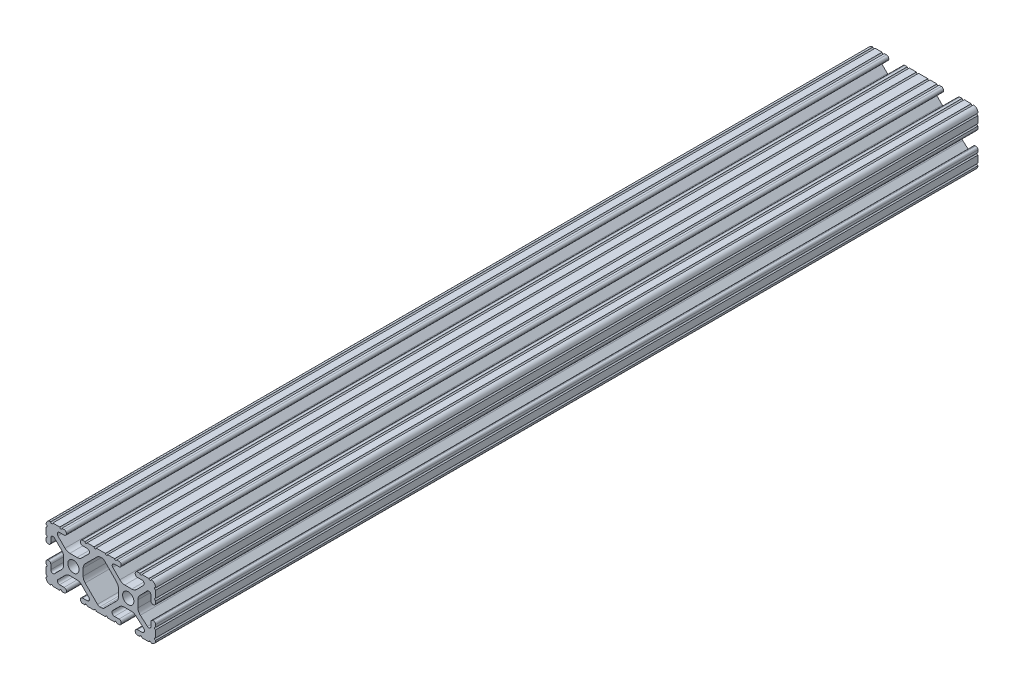
from build123d import *

# Parameters (mm, degrees)
SKETCH1_R           = 2.6035
BOSS_EXTRUDE1_DEPTH = 190.5


with BuildPart() as part:
    # Sketch1 → Boss-Extrude1 (new body, symmetric)
    with BuildSketch(Plane.XY):
        with BuildLine():
            Line((18.01710265, 12.7), (16.98745015, 12.7))
            ThreePointArc((16.98745015, 12.7), (16.245730386, 12.392769614), (15.9385, 11.65104985))
            Line((15.9385, 11.65104985), (15.9385, 11.53922))
            ThreePointArc((15.9385, 11.53922), (16.245750844, 10.797450844), (16.98752, 10.4902))
            Line((16.98752, 10.4902), (19.116384363, 10.4902))
            ThreePointArc((19.116384363, 10.4902), (20.052502933, 9.869096983), (19.844087081, 8.765172272))
            Line((19.844087081, 8.765172272), (16.618993479, 5.455112286))
            ThreePointArc((16.618993479, 5.455112286), (15.578994274, 4.745442459), (14.344932584, 4.4958))
            Line((14.344932584, 4.4958), (11.083317835, 4.4958))
            ThreePointArc((11.083317835, 4.4958), (9.854330953, 4.743306833), (8.816955189, 5.447238587))
            Line((8.816955189, 5.447238587), (5.564154119, 8.762652677))
            ThreePointArc((5.564154119, 8.762652677), (5.352591412, 9.867473037), (6.289393385, 10.4902))
            Line((6.289393385, 10.4902), (8.41248, 10.4902))
            ThreePointArc((8.41248, 10.4902), (9.154249156, 10.797450844), (9.4615, 11.53922))
            Line((9.4615, 11.53922), (9.4615, 11.65104985))
            ThreePointArc((9.4615, 11.65104985), (9.154269614, 12.392769614), (8.41254985, 12.7))
            Line((8.41254985, 12.7), (7.38288465, 12.7))
            ThreePointArc((7.38288465, 12.7), (6.87488465, 12.192), (6.36688465, 12.7))
            Line((6.36688465, 12.7), (3.14958095, 12.7))
            ThreePointArc((3.14958095, 12.7), (2.64158095, 12.192), (2.13358095, 12.7))
            Line((2.13358095, 12.7), (-2.13358095, 12.7))
            ThreePointArc((-2.13358095, 12.7), (-2.64158095, 12.192), (-3.14958095, 12.7))
            Line((-3.14958095, 12.7), (-6.36689735, 12.7))
            ThreePointArc((-6.36689735, 12.7), (-6.87489735, 12.192), (-7.38289735, 12.7))
            Line((-7.38289735, 12.7), (-8.41254985, 12.7))
            ThreePointArc((-8.41254985, 12.7), (-9.154269614, 12.392769614), (-9.4615, 11.65104985))
            Line((-9.4615, 11.65104985), (-9.4615, 11.53922))
            ThreePointArc((-9.4615, 11.53922), (-9.154249156, 10.797450844), (-8.41248, 10.4902))
            Line((-8.41248, 10.4902), (-6.283641037, 10.4902))
            ThreePointArc((-6.283641037, 10.4902), (-5.297291557, 9.829633109), (-5.532576693, 8.666071843))
            Line((-5.532576693, 8.666071843), (-8.809985098, 5.416263103))
            ThreePointArc((-8.809985098, 5.416263103), (-9.836720513, 4.734920264), (-11.045536121, 4.4958))
            Line((-11.045536121, 4.4958), (-14.354463879, 4.4958))
            ThreePointArc((-14.354463879, 4.4958), (-15.563279487, 4.734920264), (-16.590014902, 5.416263103))
            Line((-16.590014902, 5.416263103), (-19.867423307, 8.666071843))
            ThreePointArc((-19.867423307, 8.666071843), (-20.102708443, 9.829633109), (-19.116358963, 10.4902))
            Line((-19.116358963, 10.4902), (-16.98752, 10.4902))
            ThreePointArc((-16.98752, 10.4902), (-16.245750844, 10.797450844), (-15.9385, 11.53922))
            Line((-15.9385, 11.53922), (-15.9385, 11.65104985))
            ThreePointArc((-15.9385, 11.65104985), (-16.245730386, 12.392769614), (-16.98745015, 12.7))
            Line((-16.98745015, 12.7), (-18.01711535, 12.7))
            ThreePointArc((-18.01711535, 12.7), (-18.52511535, 12.192), (-19.03311535, 12.7))
            Line((-19.03311535, 12.7), (-22.2504, 12.7))
            ThreePointArc((-22.2504, 12.7), (-22.758323491, 12.192000006), (-23.266399977, 12.699846982))
            ThreePointArc((-23.266399977, 12.699846982), (-24.782522516, 12.082522516), (-25.399846982, 10.566399977))
            ThreePointArc((-25.399846982, 10.566399977), (-24.892000006, 10.058323491), (-25.4, 9.5504))
            Line((-25.4, 9.5504), (-25.4, 6.3330836))
            ThreePointArc((-25.4, 6.3330836), (-24.892, 5.8250836), (-25.4, 5.3170836))
            Line((-25.4, 5.3170836), (-25.4, 4.237520184))
            ThreePointArc((-25.4, 4.237520184), (-25.107393763, 3.531106237), (-24.400979816, 3.2385))
            Line((-24.400979816, 3.2385), (-24.23922, 3.2385))
            ThreePointArc((-24.23922, 3.2385), (-23.497450844, 3.545750844), (-23.1902, 4.28752))
            Line((-23.1902, 4.28752), (-23.1902, 6.334741132))
            ThreePointArc((-23.1902, 6.334741132), (-22.556026952, 7.286023527), (-21.434002553, 7.066535717))
            Line((-21.434002553, 7.066535717), (-18.147950853, 3.808156468))
            ThreePointArc((-18.147950853, 3.808156468), (-17.452759693, 2.774838327), (-17.208501877, 1.553619571))
            Line((-17.208501877, 1.553619571), (-17.208501877, -1.695179196))
            ThreePointArc((-17.208501877, -1.695179196), (-17.450738657, -2.911536421), (-18.140486065, -3.942289578))
            Line((-18.140486065, -3.942289578), (-21.431579576, -7.227386226))
            ThreePointArc((-21.431579576, -7.227386226), (-22.55444896, -7.449940594), (-23.1902, -6.498002195))
            Line((-23.1902, -6.498002195), (-23.1902, -4.28752))
            ThreePointArc((-23.1902, -4.28752), (-23.497450844, -3.545750844), (-24.23922, -3.2385))
            Line((-24.23922, -3.2385), (-24.35098, -3.2385))
            ThreePointArc((-24.35098, -3.2385), (-25.092749156, -3.545750844), (-25.4, -4.28752))
            Line((-25.4, -4.28752), (-25.4, -5.3171344))
            ThreePointArc((-25.4, -5.3171344), (-24.892, -5.8251344), (-25.4, -6.3331344))
            Line((-25.4, -6.3331344), (-25.4, -9.5504))
            ThreePointArc((-25.4, -9.5504), (-24.892000006, -10.058323491), (-25.399846982, -10.566399977))
            ThreePointArc((-25.399846982, -10.566399977), (-24.782522516, -12.082522516), (-23.266399977, -12.699846982))
            ThreePointArc((-23.266399977, -12.699846982), (-22.758323491, -12.192000006), (-22.2504, -12.7))
            Line((-22.2504, -12.7), (-19.03308995, -12.7))
            ThreePointArc((-19.03308995, -12.7), (-18.52508995, -12.192), (-18.01708995, -12.7))
            Line((-18.01708995, -12.7), (-16.9874692, -12.7))
            ThreePointArc((-16.9874692, -12.7), (-16.245700044, -12.392749156), (-15.9384492, -11.65098))
            Line((-15.9384492, -11.65098), (-15.9384492, -11.53922))
            ThreePointArc((-15.9384492, -11.53922), (-16.245700044, -10.797450844), (-16.9874692, -10.4902))
            Line((-16.9874692, -10.4902), (-19.116358963, -10.4902))
            ThreePointArc((-19.116358963, -10.4902), (-20.055197748, -9.862578342), (-19.834124023, -8.755124678))
            Line((-19.834124023, -8.755124678), (-16.49660751, -5.423689618))
            ThreePointArc((-16.49660751, -5.423689618), (-15.467274017, -4.736928798), (-14.253591699, -4.4958))
            Line((-14.253591699, -4.4958), (-11.146408301, -4.4958))
            ThreePointArc((-11.146408301, -4.4958), (-9.932725983, -4.736928798), (-8.90339249, -5.423689618))
            Line((-8.90339249, -5.423689618), (-5.565875977, -8.755124678))
            ThreePointArc((-5.565875977, -8.755124678), (-5.344802252, -9.862578342), (-6.283641037, -10.4902))
            Line((-6.283641037, -10.4902), (-8.4125308, -10.4902))
            ThreePointArc((-8.4125308, -10.4902), (-9.154299956, -10.797450844), (-9.4615508, -11.53922))
            Line((-9.4615508, -11.53922), (-9.4615508, -11.65098))
            ThreePointArc((-9.4615508, -11.65098), (-9.154299956, -12.392749156), (-8.4125308, -12.7))
            Line((-8.4125308, -12.7), (-7.38287195, -12.7))
            ThreePointArc((-7.38287195, -12.7), (-6.87487195, -12.192), (-6.36687195, -12.7))
            Line((-6.36687195, -12.7), (-3.14960635, -12.7))
            ThreePointArc((-3.14960635, -12.7), (-2.64160635, -12.192), (-2.13360635, -12.7))
            Line((-2.13360635, -12.7), (2.13360635, -12.7))
            ThreePointArc((2.13360635, -12.7), (2.64159365, -12.1920127), (3.14958095, -12.7))
            Line((3.14958095, -12.7), (6.36691005, -12.7))
            ThreePointArc((6.36691005, -12.7), (6.87491005, -12.192), (7.38291005, -12.7))
            Line((7.38291005, -12.7), (8.4125308, -12.7))
            ThreePointArc((8.4125308, -12.7), (9.154299956, -12.392749156), (9.4615508, -11.65098))
            Line((9.4615508, -11.65098), (9.4615508, -11.53922))
            ThreePointArc((9.4615508, -11.53922), (9.154299956, -10.797450844), (8.4125308, -10.4902))
            Line((8.4125308, -10.4902), (6.289393385, -10.4902))
            ThreePointArc((6.289393385, -10.4902), (5.231590322, -9.783049717), (5.480677245, -8.535265862))
            Line((5.480677245, -8.535265862), (8.597933595, -5.423689618))
            ThreePointArc((8.597933595, -5.423689618), (9.627267088, -4.736928798), (10.840949406, -4.4958))
            Line((10.840949406, -4.4958), (14.102564155, -4.4958))
            ThreePointArc((14.102564155, -4.4958), (15.215927525, -4.697410182), (16.187895372, -5.276636531))
            Line((16.187895372, -5.276636531), (19.868247549, -8.482246082))
            ThreePointArc((19.868247549, -8.482246082), (20.188435806, -9.746879864), (19.116384363, -10.4902))
            Line((19.116384363, -10.4902), (16.9874692, -10.4902))
            ThreePointArc((16.9874692, -10.4902), (16.245700044, -10.797450844), (15.9384492, -11.53922))
            Line((15.9384492, -11.53922), (15.9384492, -11.65098))
            ThreePointArc((15.9384492, -11.65098), (16.245700044, -12.392749156), (16.9874692, -12.7))
            Line((16.9874692, -12.7), (18.01710265, -12.7))
            ThreePointArc((18.01710265, -12.7), (18.52510265, -12.192), (19.03310265, -12.7))
            Line((19.03310265, -12.7), (22.2504, -12.7))
            ThreePointArc((22.2504, -12.7), (22.758323491, -12.192000006), (23.266399977, -12.699846982))
            ThreePointArc((23.266399977, -12.699846982), (24.782522516, -12.082522516), (25.399846982, -10.566399977))
            ThreePointArc((25.399846982, -10.566399977), (24.892000006, -10.058323492), (25.4, -9.550400001))
            Line((25.4, -9.550400001), (25.4, -6.333083592))
            ThreePointArc((25.4, -6.333083592), (24.892000001, -5.825083593), (25.4, -5.317083593))
            Line((25.4, -5.317083593), (25.4, -4.237520184))
            ThreePointArc((25.4, -4.237520184), (25.107393763, -3.531106237), (24.400979816, -3.2385))
            Line((24.400979816, -3.2385), (24.189220184, -3.2385))
            ThreePointArc((24.189220184, -3.2385), (23.482806237, -3.531106237), (23.1902, -4.237520184))
            Line((23.1902, -4.237520184), (23.1902, -6.155876159))
            ThreePointArc((23.1902, -6.155876159), (22.62232736, -7.038258539), (21.583974541, -6.886926384))
            Line((21.583974541, -6.886926384), (18.29817066, -4.024970844))
            ThreePointArc((18.29817066, -4.024970844), (17.493730985, -2.946044689), (17.208501877, -1.630807374))
            Line((17.208501877, -1.630807374), (17.208501877, 1.630807374))
            ThreePointArc((17.208501877, 1.630807374), (17.442348332, 2.82673414), (18.109440981, 3.846495088))
            Line((18.109440981, 3.846495088), (21.526346532, 7.353420386))
            ThreePointArc((21.526346532, 7.353420386), (22.585896263, 7.574939077), (23.1902, 6.676867167))
            Line((23.1902, 6.676867167), (23.1902, 4.237520184))
            ThreePointArc((23.1902, 4.237520184), (23.482806237, 3.531106237), (24.189220184, 3.2385))
            Line((24.189220184, 3.2385), (24.400979816, 3.2385))
            ThreePointArc((24.400979816, 3.2385), (25.107393763, 3.531106237), (25.4, 4.237520184))
            Line((25.4, 4.237520184), (25.4, 5.3170836))
            ThreePointArc((25.4, 5.3170836), (24.891949193, 5.825134407), (25.4, 6.333185215))
            Line((25.4, 6.333185215), (25.4, 9.550400015))
            ThreePointArc((25.4, 9.550400015), (24.892000013, 10.058323498), (25.399846982, 10.566399977))
            ThreePointArc((25.399846982, 10.566399977), (24.782522516, 12.082522516), (23.266399977, 12.699846982))
            ThreePointArc((23.266399977, 12.699846982), (22.758323491, 12.192000006), (22.2504, 12.7))
            Line((22.2504, 12.7), (19.03310265, 12.7))
            ThreePointArc((19.03310265, 12.7), (18.52510265, 12.192), (18.01710265, 12.7))
        make_face()
        with Locations((-12.7, 0)):
            Circle(SKETCH1_R, mode=Mode.SUBTRACT)
        with Locations((12.7, 0)):
            Circle(SKETCH1_R, mode=Mode.SUBTRACT)
        with BuildLine():
            Line((-7.259513935, -3.869413038), (-1.545748891, -9.572766749))
            ThreePointArc((-1.545748891, -9.572766749), (-1.035199478, -9.913400116), (-0.433213048, -10.033))
            Line((-0.433213048, -10.033), (0.433213048, -10.033))
            ThreePointArc((0.433213048, -10.033), (1.035199478, -9.913400116), (1.545748891, -9.572766749))
            Line((1.545748891, -9.572766749), (7.259513935, -3.869413038))
            ThreePointArc((7.259513935, -3.869413038), (7.949261343, -2.838659881), (8.191498123, -1.622302656))
            Line((8.191498123, -1.622302656), (8.191498123, 1.622302656))
            ThreePointArc((8.191498123, 1.622302656), (7.955573352, 2.823327967), (7.282860769, 3.845864069))
            Line((7.282860769, 3.845864069), (1.675572808, 9.561086461))
            ThreePointArc((1.675572808, 9.561086461), (1.161034429, 9.910236611), (0.551456936, 10.033))
            Line((0.551456936, 10.033), (-0.395199982, 10.033))
            ThreePointArc((-0.395199982, 10.033), (-0.994772524, 9.914396349), (-1.50403329, 9.576450301))
            Line((-1.50403329, 9.576450301), (-7.252049147, 3.876839553))
            ThreePointArc((-7.252049147, 3.876839553), (-7.947240307, 2.843521412), (-8.191498123, 1.622302656))
            Line((-8.191498123, 1.622302656), (-8.191498123, -1.622302656))
            ThreePointArc((-8.191498123, -1.622302656), (-7.949261343, -2.838659881), (-7.259513935, -3.869413038))
        make_face(mode=Mode.SUBTRACT)
    extrude(amount=BOSS_EXTRUDE1_DEPTH, both=True)


solid = part.part
